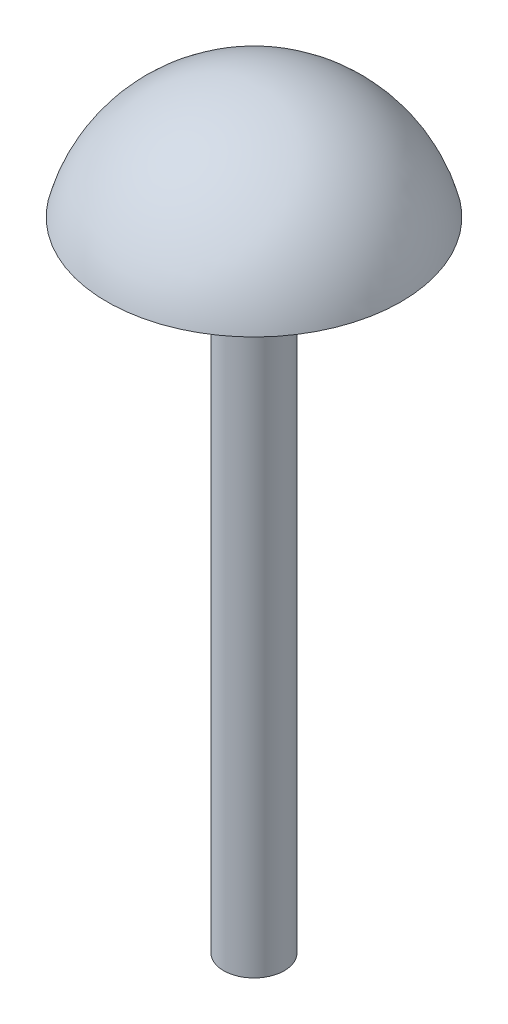
from build123d import *


with BuildPart() as part:
    # Sketch1 → Revolve1 (revolve)
    with BuildSketch(Plane.XY):
        with BuildLine():
            Line((0, 0), (0.60801932, 0))
            Line((0.60801932, 0), (0.60801932, 12.739639126))
            Line((0.60801932, 12.739639126), (2.937339451, 12.739639126))
            ThreePointArc((2.937339451, 12.739639126), (1.858702512, 14.381675744), (0, 15.018045819))
            Line((0, 15.018045819), (0, 0))
        make_face()
    revolve(axis=Axis((0, 0, 0), (0, 1, 0)))


solid = part.part
